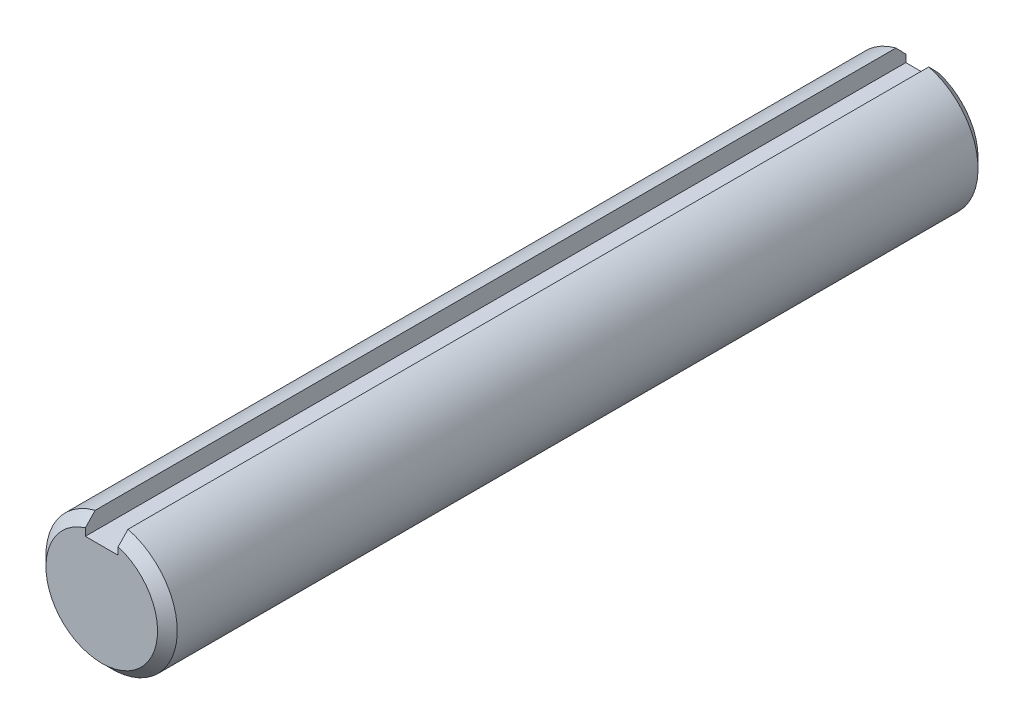
from build123d import *

# Parameters (mm, degrees)
SKETCH1_R           = 4
EXTRUDE1_DEPTH      = 25
CHAMFER1_SIZE       = 0.6
SKETCH3_W           = 2
SKETCH3_H           = 1.2
EXTRUDE2_DEPTH      = 26
EXTRUDE2_DEPTH_BACK = 26


with BuildPart() as part:
    # Sketch1 → Extrude1 (new body, symmetric)
    with BuildSketch(Plane.XY):
        Circle(SKETCH1_R)
    extrude(amount=EXTRUDE1_DEPTH, both=True)

    # Chamfer1
    chamfer1_edges = [part.edges().sort_by_distance(p)[0] for p in [
        (-4, 0, -25),
        (-4, 0, 25),
    ]]
    chamfer(chamfer1_edges, length=CHAMFER1_SIZE)

    # Sketch3 → Extrude2 (cut, two sides)
    with BuildSketch(Plane.XY) as extrude2_sk:
        with Locations((0, 3.4)):
            Rectangle(SKETCH3_W, SKETCH3_H)
    extrude(amount=EXTRUDE2_DEPTH, mode=Mode.SUBTRACT)
    extrude(extrude2_sk.sketch, amount=-EXTRUDE2_DEPTH_BACK, mode=Mode.SUBTRACT)


solid = part.part
